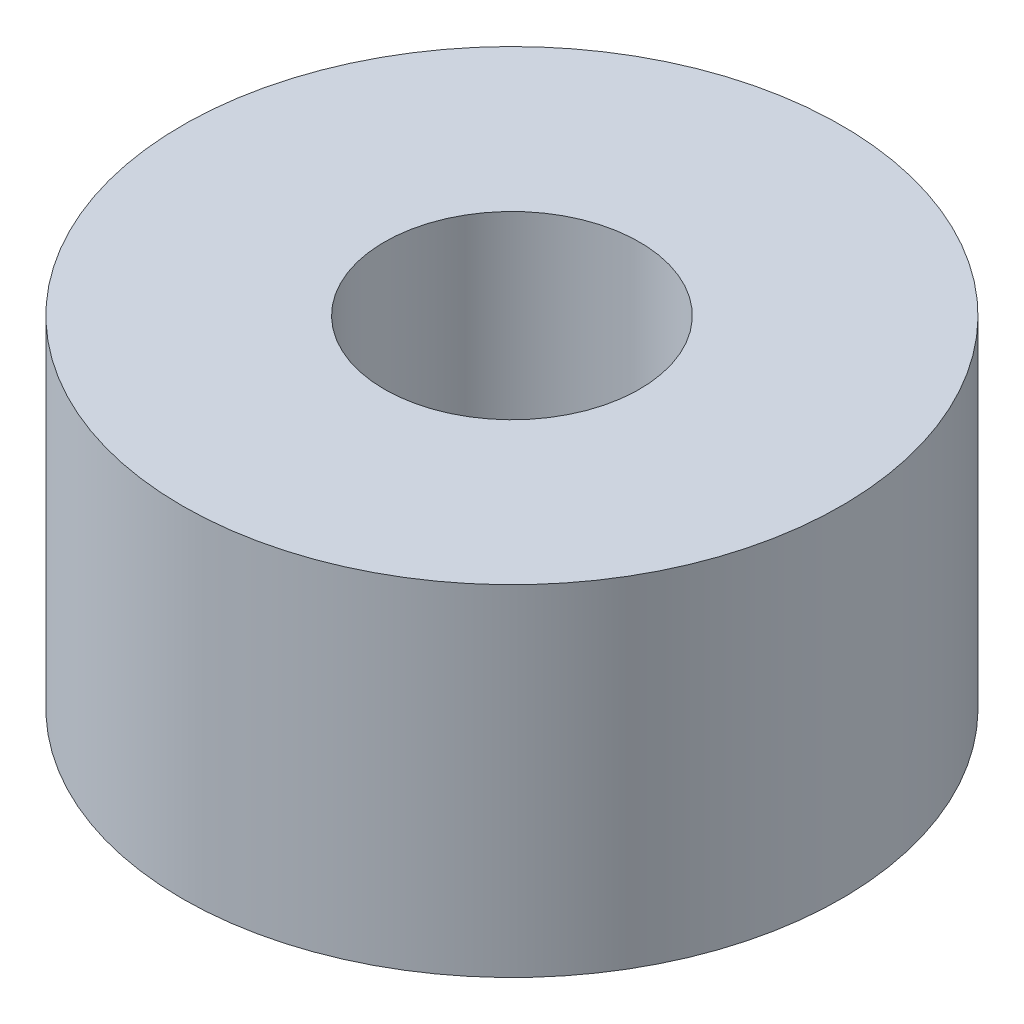
from build123d import *

# Parameters (mm, degrees)
SKETCH1_R           = 3.937
SKETCH1_R_2         = 1.524
BOSS_EXTRUDE1_DEPTH = 4.064


with BuildPart() as part:
    # Sketch1 → Boss-Extrude1 (new body)
    with BuildSketch(Plane(origin=(0, 0, 0), x_dir=(1, 0, 0), z_dir=(0, 1, 0))):
        Circle(SKETCH1_R)
        Circle(SKETCH1_R_2, mode=Mode.SUBTRACT)
    extrude(amount=BOSS_EXTRUDE1_DEPTH)


solid = part.part
